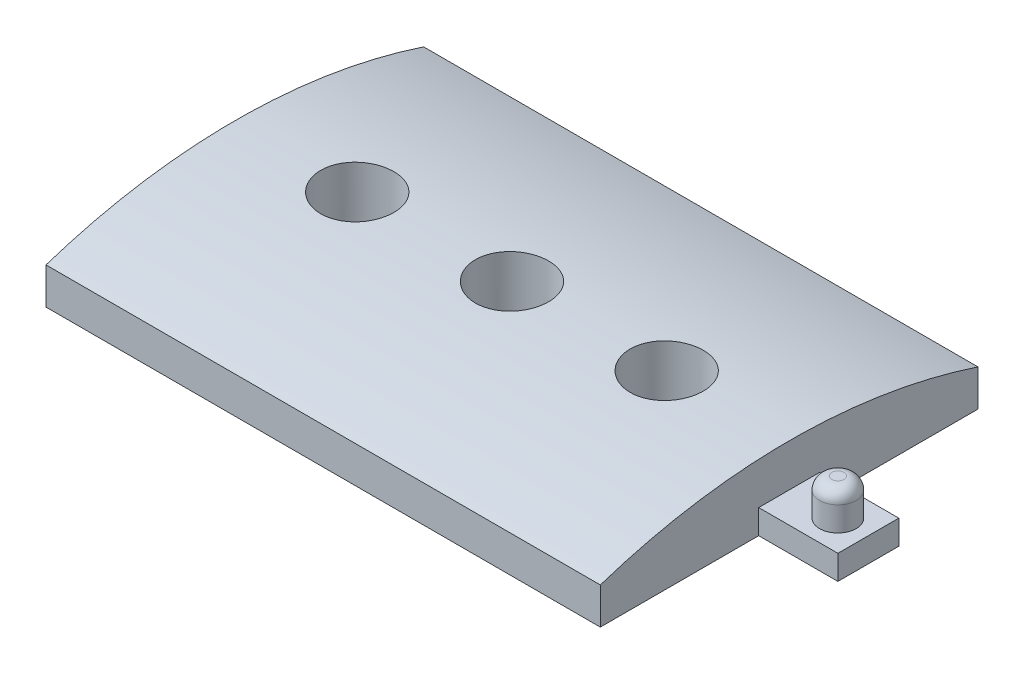
from build123d import *

# Parameters (mm, degrees)
SKETCH1_W           = 91
SKETCH1_H           = 62
SKETCH1_R           = 6
BOSS_EXTRUDE1_DEPTH = 6
SKETCH16_W          = 3
SKETCH16_H          = 10
SKETCH16_W_2        = 10
SKETCH16_R          = 3
BOSS_EXTRUDE3_DEPTH = 4
SKETCH16_4_R        = 3
BOSS_EXTRUDE4_DEPTH = 10
FILLET1_R           = 2
BOSS_EXTRUDE5_DEPTH = 91
SKETCH1_2_R         = 6
CUT_EXTRUDE1_DEPTH  = 12


with BuildPart() as part:
    # Sketch1 → Boss-Extrude1 (new body)
    with BuildSketch(Plane(origin=(0, 0, 0), x_dir=(1, 0, 0), z_dir=(0, 1, 0))):
        Rectangle(SKETCH1_W, SKETCH1_H)
        with Locations((-25.4, 0)):
            Circle(SKETCH1_R, mode=Mode.SUBTRACT)
        Circle(SKETCH1_R, mode=Mode.SUBTRACT)
        with Locations((25.4, 0)):
            Circle(SKETCH1_R, mode=Mode.SUBTRACT)
    extrude(amount=BOSS_EXTRUDE1_DEPTH)

    # Sketch16 → Boss-Extrude3 (add)
    with BuildSketch(Plane.XZ):
        with Locations((47, 0)):
            Rectangle(SKETCH16_W, SKETCH16_H)
        with Locations((53.5, 0)):
            Rectangle(SKETCH16_W_2, SKETCH16_H)
        with Locations((53.5, 0)):
            Circle(SKETCH16_R, mode=Mode.SUBTRACT)
        with Locations((53.5, 0)):
            Circle(SKETCH16_R)
    extrude(amount=-BOSS_EXTRUDE3_DEPTH)

    # Sketch16_4 → Boss-Extrude4 (add)
    with BuildSketch(Plane.XZ):
        with Locations((53.5, 0)):
            Circle(SKETCH16_4_R)
    extrude(amount=-BOSS_EXTRUDE4_DEPTH)

    # Fillet1
    fillet1_edges = [part.edges().sort_by_distance(p)[0] for p in [
        (50.5, 10, 0),
    ]]
    fillet(fillet1_edges, radius=FILLET1_R)

    # Sketch17 → Boss-Extrude5 (add)
    with BuildSketch(Plane.ZY.offset(45.5)):
        with BuildLine():
            Line((-31, 6), (31, 6))
            ThreePointArc((31, 6), (0, 11), (-31, 6))
        make_face()
    extrude(amount=-BOSS_EXTRUDE5_DEPTH)

    # Sketch1_2 → Cut-Extrude1 (cut, through all)
    with BuildSketch(Plane(origin=(0, 0, 0), x_dir=(1, 0, 0), z_dir=(0, 1, 0))):
        with Locations((-25.4, 0)):
            Circle(SKETCH1_2_R)
        Circle(SKETCH1_2_R)
        with Locations((25.4, 0)):
            Circle(SKETCH1_2_R)
    extrude(amount=CUT_EXTRUDE1_DEPTH, mode=Mode.SUBTRACT)


solid = part.part
